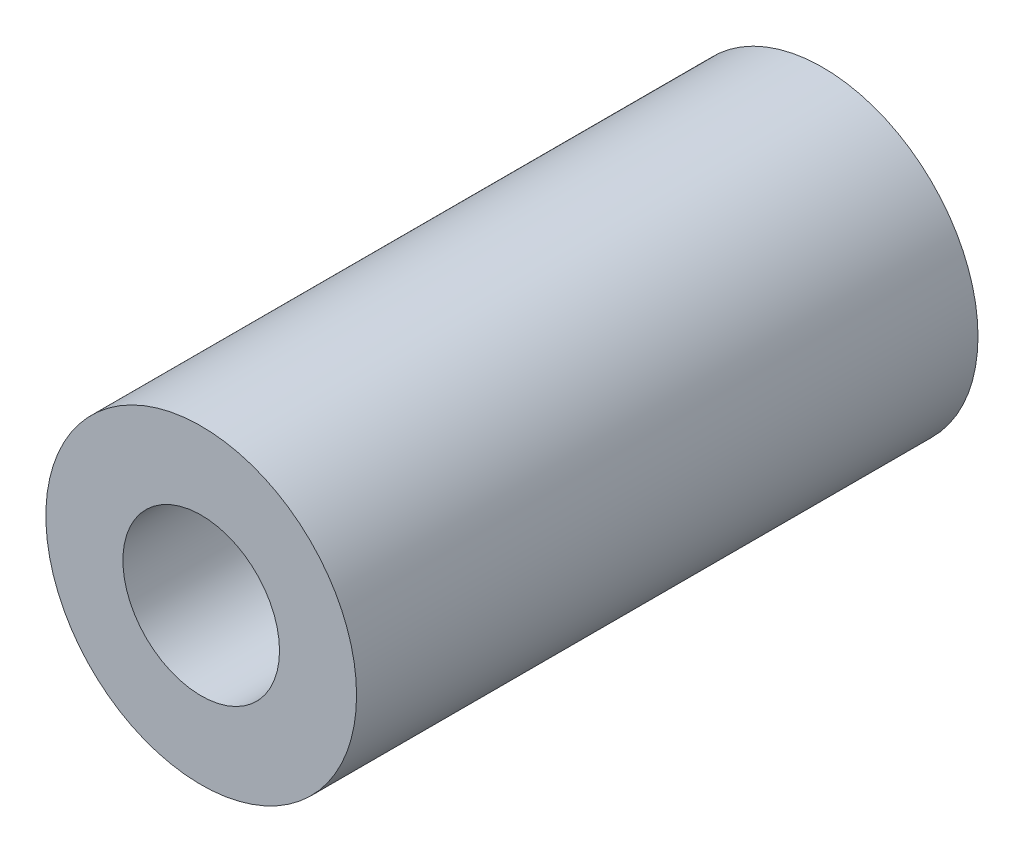
from build123d import *

# Parameters (mm, degrees)
SKETCH1_R      = 6.35
SKETCH1_R_2    = 3.2004
EXTRUDE1_DEPTH = 12.7


with BuildPart() as part:
    # Sketch1 → Extrude1 (new body, symmetric)
    with BuildSketch(Plane.XY):
        Circle(SKETCH1_R)
        Circle(SKETCH1_R_2, mode=Mode.SUBTRACT)
    extrude(amount=EXTRUDE1_DEPTH, both=True)


solid = part.part
